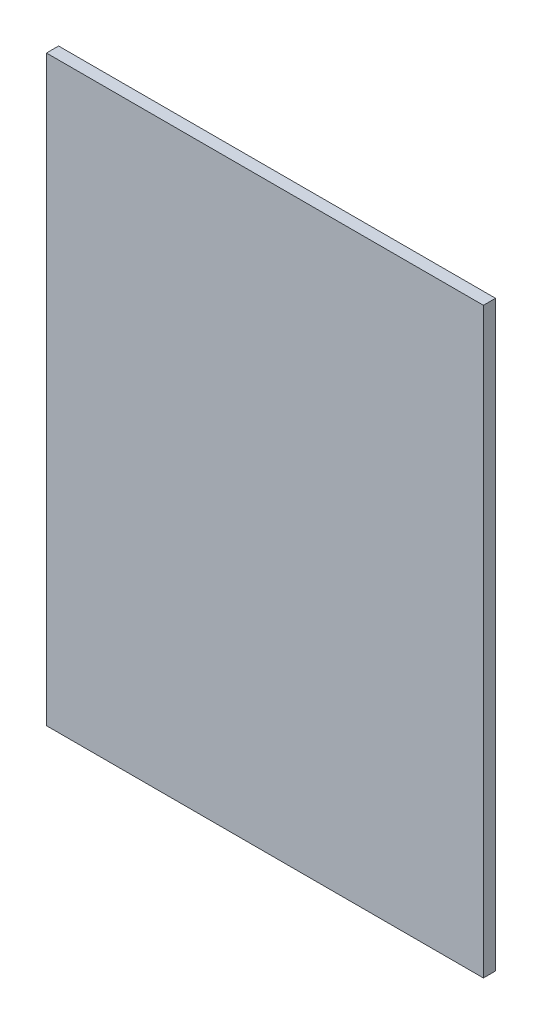
from build123d import *

# Parameters (mm, degrees)
SKETCH1_W           = 914.4
SKETCH1_H           = 1219.2
BOSS_EXTRUDE1_DEPTH = 25.4


with BuildPart() as part:
    # Sketch1 → Boss-Extrude1 (new body)
    with BuildSketch(Plane.XY):
        with Locations((457.2, -609.6)):
            Rectangle(SKETCH1_W, SKETCH1_H)
    extrude(amount=BOSS_EXTRUDE1_DEPTH)


solid = part.part
